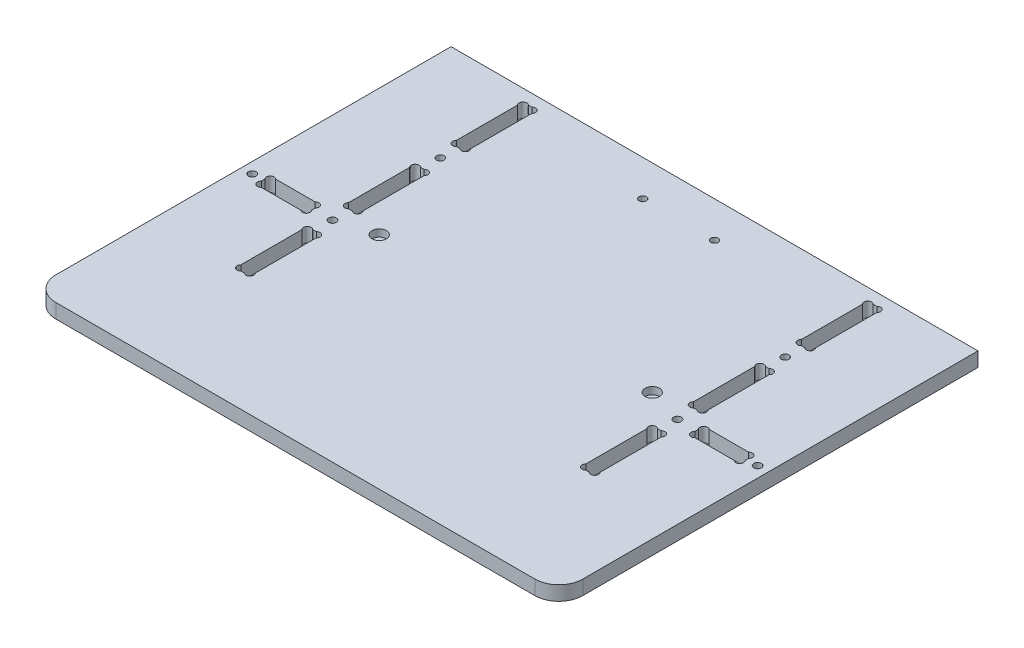
from build123d import *

# Parameters (mm, degrees)
ESQUISSE2_R             = 1.6
EXTRUSION1_DEPTH        = 6
ESQUISSE4_R             = 1.53
ESQUISSE4_R_2           = 3
ENL_V_MAT_EXTRU_1_DEPTH = 3


with BuildPart() as part:
    # Esquisse2 → Extrusion1 (new body)
    with BuildSketch(Plane(origin=(0, 0, 0), x_dir=(1, 0, 0), z_dir=(0, 1, 0))):
        with BuildLine():
            Line((-20, -45), (180, -45))
            ThreePointArc((180, -45), (187.071067812, -42.071067812), (190, -35))
            Line((190, -35), (190, 130))
            Line((190, 130), (-30, 130))
            Line((-30, 130), (-30, -35))
            ThreePointArc((-30, -35), (-27.071067812, -42.071067812), (-20, -45))
        make_face()
        with Locations(Location((8, 87.5, 0), (0, 0, 270))):  # turned: the seam where the file's is
            Circle(ESQUISSE2_R, mode=Mode.SUBTRACT)
        with Locations(Location((8, 42.5, 0), (0, 0, 90))):  # turned: the seam where the file's is
            Circle(ESQUISSE2_R, mode=Mode.SUBTRACT)
        with Locations(Location((152, 42.5, 0), (0, 0, 270))):  # turned: the seam where the file's is
            Circle(ESQUISSE2_R, mode=Mode.SUBTRACT)
        with Locations(Location((152, 87.5, 0), (0, 0, 90))):  # turned: the seam where the file's is
            Circle(ESQUISSE2_R, mode=Mode.SUBTRACT)
        with Locations(Location((-25.5, 42.5, 0), (0, 0, 270))):  # turned: the seam where the file's is
            Circle(ESQUISSE2_R, mode=Mode.SUBTRACT)
        with Locations(Location((185.5, 42.5, 0), (0, 0, 90))):  # turned: the seam where the file's is
            Circle(ESQUISSE2_R, mode=Mode.SUBTRACT)
        with BuildLine():
            Line((7.2627417, 125), (8.7372583, 125))
            ThreePointArc((8.7372583, 125), (11, 125), (11, 122.7372583))
            Line((11, 122.7372583), (11, 97.2627417))
            ThreePointArc((11, 97.2627417), (11, 95), (8.7372583, 95))
            Line((8.7372583, 95), (7.2627417, 95))
            ThreePointArc((7.2627417, 95), (5, 95), (5, 97.2627417))
            Line((5, 97.2627417), (5, 122.7372583))
            ThreePointArc((5, 122.7372583), (5, 125), (7.2627417, 125))
        make_face(mode=Mode.SUBTRACT)
        with BuildLine():
            Line((7.2627417, 80), (8.7372583, 80))
            ThreePointArc((8.7372583, 80), (11, 80), (11, 77.7372583))
            Line((11, 77.7372583), (11, 52.2627417))
            ThreePointArc((11, 52.2627417), (11, 50), (8.7372583, 50))
            Line((8.7372583, 50), (7.2627417, 50))
            ThreePointArc((7.2627417, 50), (5, 50), (5, 52.2627417))
            Line((5, 52.2627417), (5, 77.7372583))
            ThreePointArc((5, 77.7372583), (5, 80), (7.2627417, 80))
        make_face(mode=Mode.SUBTRACT)
        with BuildLine():
            Line((8.7372583, 35), (7.2627417, 35))
            ThreePointArc((7.2627417, 35), (5, 35), (5, 32.7372583))
            Line((5, 32.7372583), (5, 7.2627417))
            ThreePointArc((5, 7.2627417), (5, 5), (7.2627417, 5))
            Line((7.2627417, 5), (8.7372583, 5))
            ThreePointArc((8.7372583, 5), (11, 5), (11, 7.2627417))
            Line((11, 7.2627417), (11, 32.7372583))
            ThreePointArc((11, 32.7372583), (11, 35), (8.7372583, 35))
        make_face(mode=Mode.SUBTRACT)
        with BuildLine():
            Line((152.7372583, 5), (151.2627417, 5))
            ThreePointArc((151.2627417, 5), (149, 5), (149, 7.2627417))
            Line((149, 7.2627417), (149, 32.7372583))
            ThreePointArc((149, 32.7372583), (149, 35), (151.2627417, 35))
            Line((151.2627417, 35), (152.7372583, 35))
            ThreePointArc((152.7372583, 35), (155, 35), (155, 32.7372583))
            Line((155, 32.7372583), (155, 7.2627417))
            ThreePointArc((155, 7.2627417), (155, 5), (152.7372583, 5))
        make_face(mode=Mode.SUBTRACT)
        with BuildLine():
            Line((155, 77.7372583), (155, 52.2627417))
            ThreePointArc((155, 52.2627417), (155, 50), (152.7372583, 50))
            Line((152.7372583, 50), (151.2627417, 50))
            ThreePointArc((151.2627417, 50), (149, 50), (149, 52.2627417))
            Line((149, 52.2627417), (149, 77.7372583))
            ThreePointArc((149, 77.7372583), (149, 80), (151.2627417, 80))
            Line((151.2627417, 80), (152.7372583, 80))
            ThreePointArc((152.7372583, 80), (155, 80), (155, 77.7372583))
        make_face(mode=Mode.SUBTRACT)
        with BuildLine():
            Line((151.2627417, 95), (152.7372583, 95))
            ThreePointArc((152.7372583, 95), (155, 95), (155, 97.2627417))
            Line((155, 97.2627417), (155, 122.7372583))
            ThreePointArc((155, 122.7372583), (155, 125), (152.7372583, 125))
            Line((152.7372583, 125), (151.2627417, 125))
            ThreePointArc((151.2627417, 125), (149, 125), (149, 122.7372583))
            Line((149, 122.7372583), (149, 97.2627417))
            ThreePointArc((149, 97.2627417), (149, 95), (151.2627417, 95))
        make_face(mode=Mode.SUBTRACT)
        with BuildLine():
            Line((181, 41.7627417), (181, 43.2372583))
            ThreePointArc((181, 43.2372583), (181, 45.5), (178.7372583, 45.5))
            Line((178.7372583, 45.5), (162.2627417, 45.5))
            ThreePointArc((162.2627417, 45.5), (160, 45.5), (160, 43.2372583))
            Line((160, 43.2372583), (160, 41.7627417))
            ThreePointArc((160, 41.7627417), (160, 39.5), (162.2627417, 39.5))
            Line((162.2627417, 39.5), (178.7372583, 39.5))
            ThreePointArc((178.7372583, 39.5), (181, 39.5), (181, 41.7627417))
        make_face(mode=Mode.SUBTRACT)
        with BuildLine():
            Line((-2.2627417, 39.5), (-18.7372583, 39.5))
            ThreePointArc((-18.7372583, 39.5), (-21, 39.5), (-21, 41.7627417))
            Line((-21, 41.7627417), (-21, 43.2372583))
            ThreePointArc((-21, 43.2372583), (-21, 45.5), (-18.7372583, 45.5))
            Line((-18.7372583, 45.5), (-2.2627417, 45.5))
            ThreePointArc((-2.2627417, 45.5), (0, 45.5), (0, 43.2372583))
            Line((0, 43.2372583), (0, 41.7627417))
            ThreePointArc((0, 41.7627417), (0, 39.5), (-2.2627417, 39.5))
        make_face(mode=Mode.SUBTRACT)
    extrude(amount=EXTRUSION1_DEPTH)

    # Esquisse4 → Enlèv. mat.-Extru.1 (cut)
    with BuildSketch(Plane(origin=(0, 6, 0), x_dir=(-1, 0, 0), z_dir=(0, 1, 0))):
        with Locations(Location((-65, -115, 0), (0, 0, 90))):  # turned: the seam where the file's is
            Circle(ESQUISSE4_R)
        with Locations(Location((-23, -47, 0), (0, 0, 90))):  # turned: the seam where the file's is
            Circle(ESQUISSE4_R_2)
        with Locations(Location((-95, -115, 0), (0, 0, 270))):  # turned: the seam where the file's is
            Circle(ESQUISSE4_R)
        with Locations(Location((-137, -47, 0), (0, 0, 270))):  # turned: the seam where the file's is
            Circle(ESQUISSE4_R_2)
    extrude(amount=-ENL_V_MAT_EXTRU_1_DEPTH, mode=Mode.SUBTRACT)


solid = part.part
